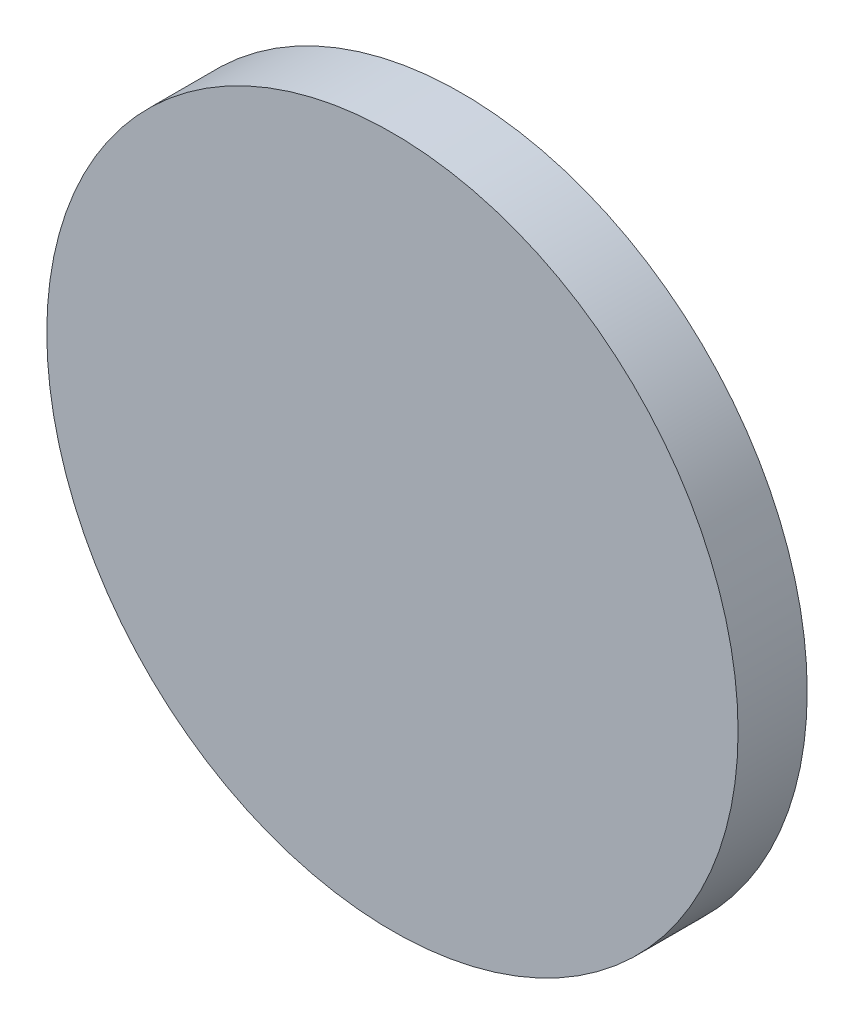
from build123d import *

# Parameters (mm, degrees)
SKETCH_1_R      = 25
EXTRUDE_1_DEPTH = 5


with BuildPart() as part:
    # 草图1 → 凸台-拉伸1 (new body)
    with BuildSketch(Plane.XY):
        Circle(SKETCH_1_R)
    extrude(amount=EXTRUDE_1_DEPTH)


solid = part.part
